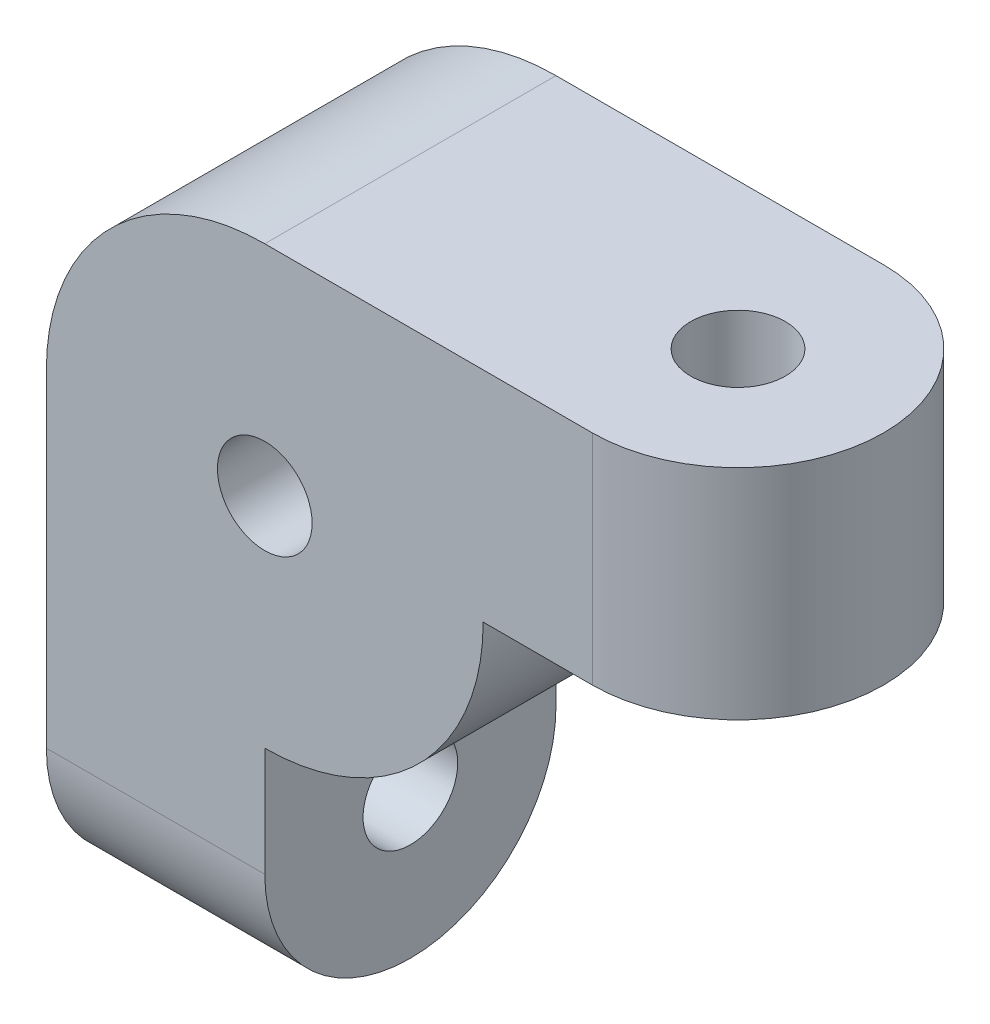
from build123d import *

# Parameters (mm, degrees)
SKETCH1_R           = 6
SKETCH1_R_2         = 1.3
BOSS_EXTRUDE1_DEPTH = 8
SKETCH4_W           = 8
SKETCH4_H           = 3
BOSS_EXTRUDE2_DEPTH = 6
BOSS_EXTRUDE4_DEPTH = 6
SKETCH12_R          = 1.3
CUT_EXTRUDE6_DEPTH  = 6
SKETCH13_R          = 1.3
CUT_EXTRUDE7_DEPTH  = 6
SKETCH14_R          = 3
CUT_EXTRUDE8_DEPTH  = 3


with BuildPart() as part:
    # Sketch1 → Boss-Extrude1 (new body)
    with BuildSketch(Plane.XY):
        Circle(SKETCH1_R)
        Circle(SKETCH1_R_2, mode=Mode.SUBTRACT)
        with BuildLine():
            ThreePointArc((0, -6), (-4.242640687, -4.242640687), (-6, 0))
            Line((-6, 0), (-6, -6))
            Line((-6, -6), (0, -6))
        make_face()
        with BuildLine():
            Line((6, 6), (0, 6))
            ThreePointArc((0, 6), (4.242640687, 4.242640687), (6, 0))
            Line((6, 0), (6, 6))
        make_face()
    extrude(amount=BOSS_EXTRUDE1_DEPTH)

    # Sketch4 → Boss-Extrude2 (add)
    with BuildSketch(Plane(origin=(0, 0, 0), x_dir=(0, 0, -1), z_dir=(1, 0, 0))):
        with Locations((-4, -7.5)):
            Rectangle(SKETCH4_W, SKETCH4_H)
        with BuildLine():
            Line((-8, -9), (0, -9))
            ThreePointArc((0, -9), (-4, -13), (-8, -9))
        make_face()
    extrude(amount=-BOSS_EXTRUDE2_DEPTH)

    # Sketch5 → Boss-Extrude4 (add)
    with BuildSketch(Plane(origin=(0, 0, 0), x_dir=(1, 0, 0), z_dir=(0, 1, 0))):
        with BuildLine():
            Line((6, 0), (9, 0))
            ThreePointArc((9, 0), (13, -4), (9, -8))
            Line((9, -8), (6, -8))
            Line((6, -8), (6, 0))
        make_face()
    extrude(amount=BOSS_EXTRUDE4_DEPTH)

    # Sketch12 → Cut-Extrude6 (cut)
    with BuildSketch(Plane.XZ):
        with Locations((9, 4)):
            Circle(SKETCH12_R)
    extrude(amount=-CUT_EXTRUDE6_DEPTH, mode=Mode.SUBTRACT)

    # Sketch13 → Cut-Extrude7 (cut)
    with BuildSketch(Plane(origin=(0, 0, 0), x_dir=(0, 0, -1), z_dir=(1, 0, 0))):
        with Locations((-4, -9)):
            Circle(SKETCH13_R)
    extrude(amount=-CUT_EXTRUDE7_DEPTH, mode=Mode.SUBTRACT)

    # Sketch14 → Cut-Extrude8 (cut)
    with BuildSketch(Plane(origin=(0, 0, 0), x_dir=(-1, 0, 0), z_dir=(0, 0, -1))):
        Circle(SKETCH14_R)
    extrude(amount=-CUT_EXTRUDE8_DEPTH, mode=Mode.SUBTRACT)


solid = part.part
